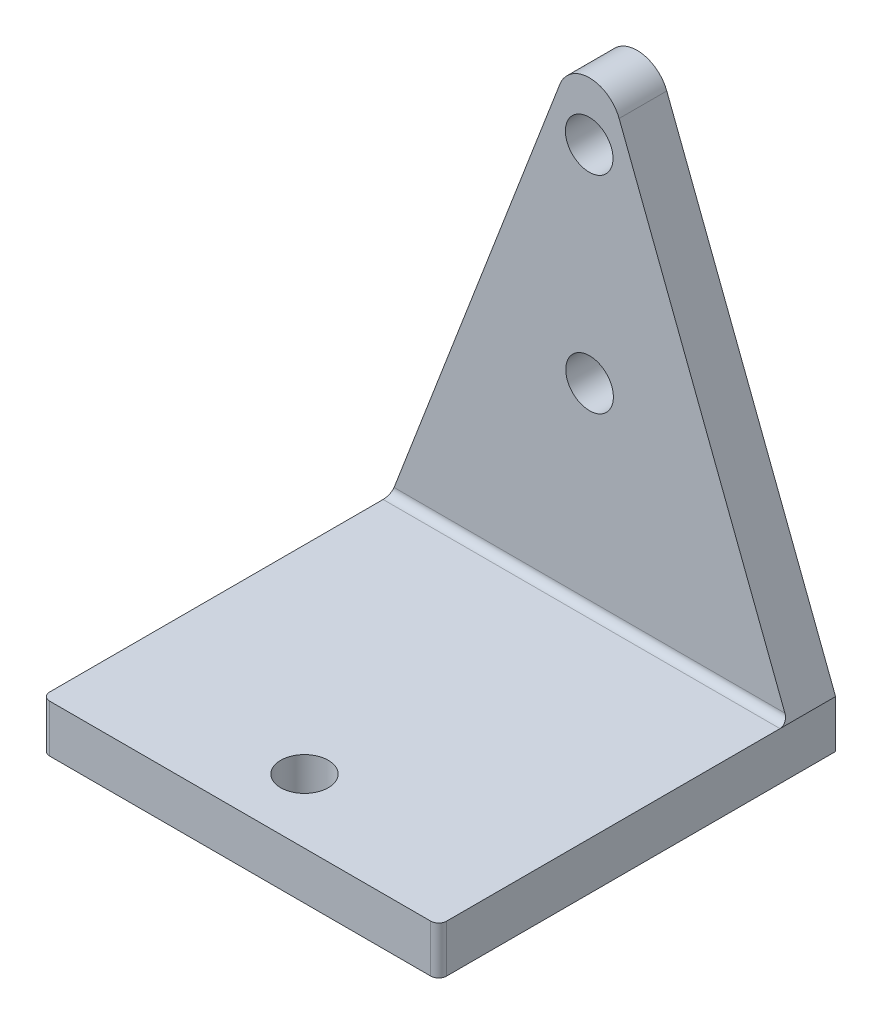
from build123d import *

# Parameters (mm, degrees)
SKETCH1_W           = 250
SKETCH1_H           = 250
EXTRUDE1_DEPTH      = 30
EXTRUDE2_DEPTH      = 30
FILLET1_R           = 5
FILLET2_R           = 5
SKETCH14_R          = 15
CUT_EXTRUDE1_DEPTH  = 30
SKETCH16_R          = 5.416442209
BOSS_EXTRUDE4_DEPTH = 30
SKETCH17_R          = 15
CUT_EXTRUDE2_DEPTH  = 30


with BuildPart() as part:
    # Sketch1 → Extrude1 (new body)
    with BuildSketch(Plane(origin=(0, 0, 0), x_dir=(1, 0, 0), z_dir=(0, 1, 0))):
        Rectangle(SKETCH1_W, SKETCH1_H)
    extrude(amount=EXTRUDE1_DEPTH)

    # Sketch3 → Extrude2 (add)
    with BuildSketch(Plane(origin=(0, 0, -125), x_dir=(-1, 0, 0), z_dir=(0, 0, -1))):
        with BuildLine():
            Line((-125, 30), (-18.673100048, 307.163472244))
            ThreePointArc((-18.673100048, 307.163472244), (0, 320), (18.673100048, 307.163472244))
            Line((18.673100048, 307.163472244), (125, 30))
            Line((125, 30), (-125, 30))
        make_face()
    extrude(amount=-EXTRUDE2_DEPTH)

    # Fillet1
    fillet1_edges = [part.edges().sort_by_distance(p)[0] for p in [
        (0, 30, -95),
    ]]
    fillet(fillet1_edges, radius=FILLET1_R)

    # Fillet2
    fillet2_edges = [part.edges().sort_by_distance(p)[0] for p in [
        (-125, 15, 125),
        (125, 15, 125),
    ]]
    fillet(fillet2_edges, radius=FILLET2_R)

    # Sketch14 → Cut-Extrude1 (cut)
    with BuildSketch(Plane.XY.offset(-95)):
        with Locations((0.050224631, 153.429955133)):
            Circle(SKETCH14_R)
        with Locations((-0.186934905, 283.429955133)):
            Circle(SKETCH14_R)
    extrude(amount=-CUT_EXTRUDE1_DEPTH, mode=Mode.SUBTRACT)

    # Sketch16 → Boss-Extrude4 (add)
    with BuildSketch(Plane(origin=(-1.938008544, 0, -95), x_dir=(1, 0, 0), z_dir=(0, 0, 1))):
        with Locations((1.836864398, 213.31214362)):
            Circle(SKETCH16_R)
    extrude(amount=-BOSS_EXTRUDE4_DEPTH)

    # Sketch17 → Cut-Extrude2 (cut)
    with BuildSketch(Plane(origin=(0, 30, 0), x_dir=(1, 0, 0), z_dir=(0, 1, 0))):
        with Locations((0, -84.507674079)):
            Circle(SKETCH17_R)
    extrude(amount=-CUT_EXTRUDE2_DEPTH, mode=Mode.SUBTRACT)


solid = part.part
